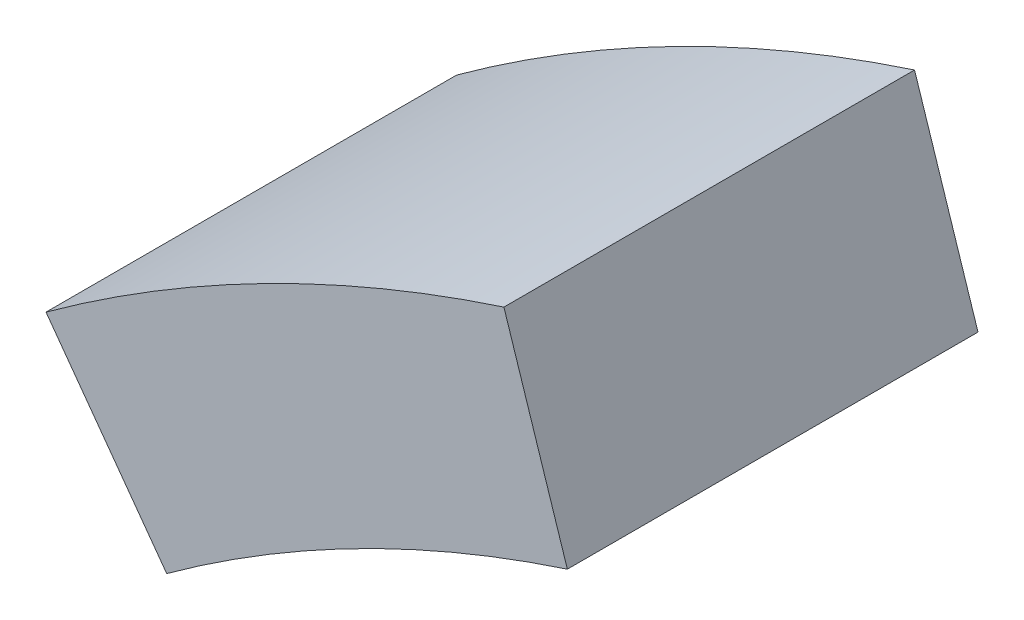
from build123d import *

# Parameters (mm, degrees)
EXTRUDE_1_DEPTH = 480
SCALE_1_SCALE   = 1.3


with BuildPart() as part:
    # 草图1 → 凸台-拉伸1 (new body)
    with BuildSketch(Plane.XY):
        with BuildLine():
            Line((-7368.547684402, 5393.3126292), (-7227.479223851, 5199.14855055))
            ThreePointArc((-7227.479223851, 5199.14855055), (-7002.704039562, 5336.890960636), (-6759.14855055, 5437.774947376))
            Line((-6759.14855055, 5437.774947376), (-6833.3126292, 5666.028511287))
            ThreePointArc((-6833.3126292, 5666.028511287), (-6989.477063432, 5607.677609574), (-7139.991111067, 5536))
            ThreePointArc((-7139.991111067, 5536), (-7256.775458313, 5468.670521429), (-7368.547684402, 5393.3126292))
        make_face()
    extrude(amount=EXTRUDE_1_DEPTH)


with BuildPart() as part_1:
    # 缩放比例1: scaled about (0, 0, 0)
    add(part.part.scale(SCALE_1_SCALE))


solid = part_1.part
